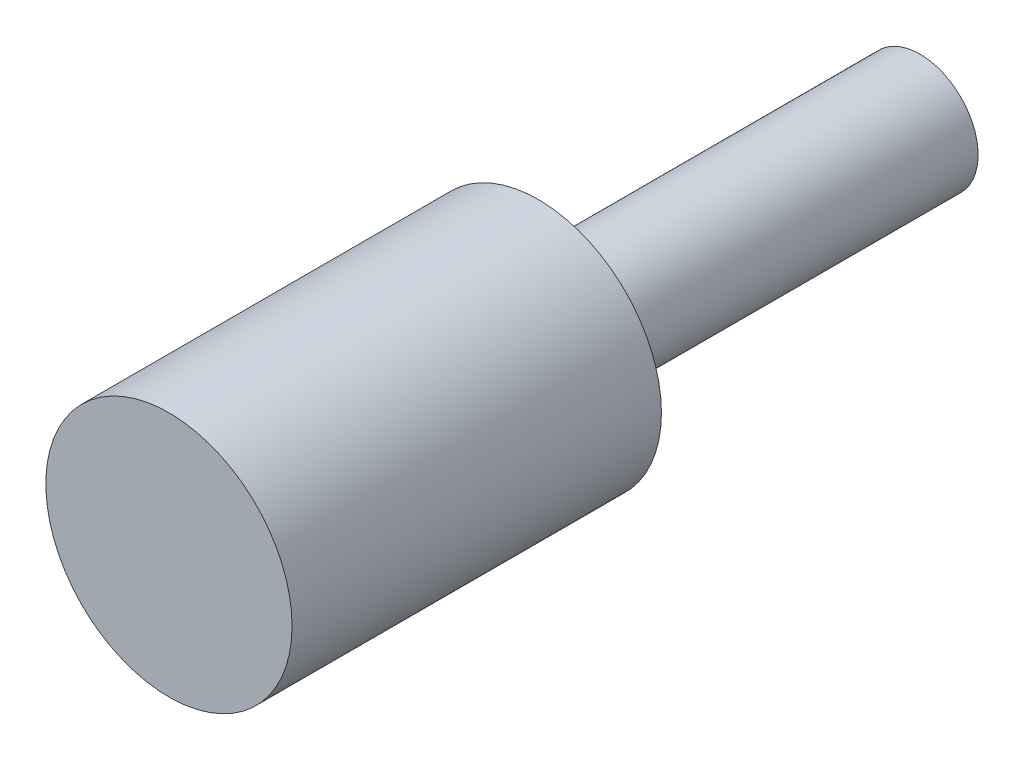
from build123d import *

# Parameters (mm, degrees)
SKETCH1_R           = 10
BOSS_EXTRUDE1_DEPTH = 30
SKETCH2_R           = 4.720805109
BOSS_EXTRUDE2_DEPTH = 31


with BuildPart() as part:
    # Sketch1 → Boss-Extrude1 (new body)
    with BuildSketch(Plane.XY):
        Circle(SKETCH1_R)
    extrude(amount=BOSS_EXTRUDE1_DEPTH)

    # Sketch2 → Boss-Extrude2 (add)
    with BuildSketch(Plane(origin=(0, 0, 0), x_dir=(-1, 0, 0), z_dir=(0, 0, -1))):
        Circle(SKETCH2_R)
    extrude(amount=BOSS_EXTRUDE2_DEPTH)


solid = part.part
